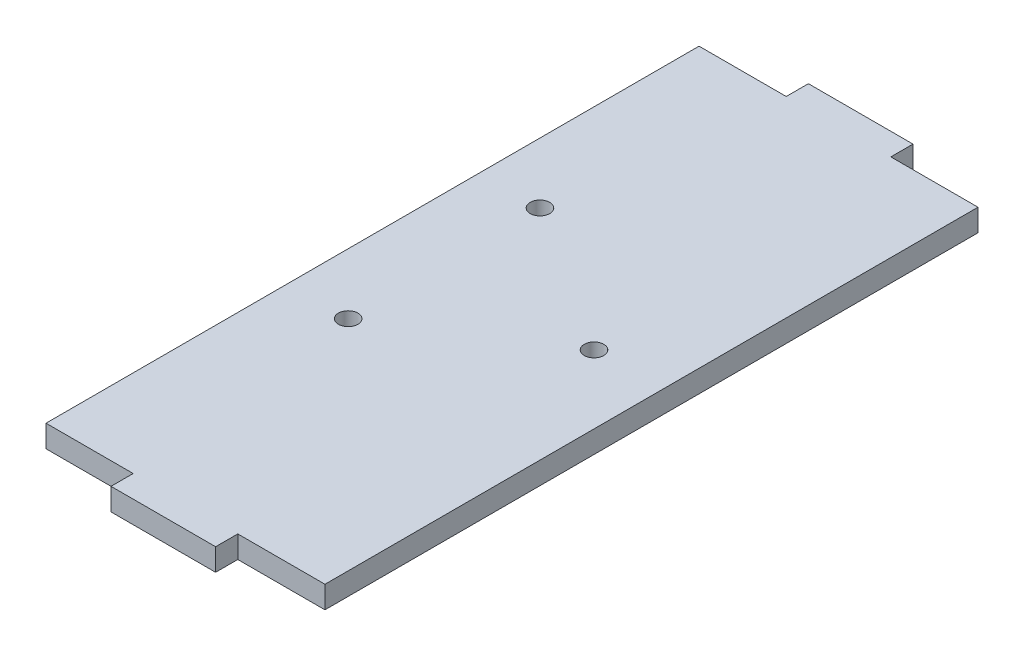
from build123d import *

# Parameters (mm, degrees)
SKETCH1_W           = 40
SKETCH1_H           = 100
BOSS_EXTRUDE1_DEPTH = 3.18
SKETCH2_W           = 12.5
SKETCH2_H           = 3.18
CUT_EXTRUDE1_DEPTH  = 4.18
SKETCH3_R           = 1.4
CUT_EXTRUDE2_DEPTH  = 4.18


with BuildPart() as part:
    # Sketch1 → Boss-Extrude1 (new body)
    with BuildSketch(Plane(origin=(0, 0, 0), x_dir=(1, 0, 0), z_dir=(0, 1, 0))):
        Rectangle(SKETCH1_W, SKETCH1_H)
    extrude(amount=BOSS_EXTRUDE1_DEPTH)

    # Sketch2 → Cut-Extrude1 (cut, through all)
    with BuildSketch(Plane(origin=(0, 3.18, 0), x_dir=(1, 0, 0), z_dir=(0, 1, 0))):
        with Locations((13.75, 48.41)):
            Rectangle(SKETCH2_W, SKETCH2_H)
        with Locations((-13.75, 48.41)):
            Rectangle(SKETCH2_W, SKETCH2_H)
    cut_extrude1 = extrude(amount=-CUT_EXTRUDE1_DEPTH, mode=Mode.SUBTRACT)

    # Mirror1: Cut-Extrude1 across plane
    add(cut_extrude1.mirror(Plane.XY), mode=Mode.SUBTRACT)

    # Sketch3 → Cut-Extrude2 (cut, through all)
    with BuildSketch(Plane(origin=(0, 3.18, 0), x_dir=(1, 0, 0), z_dir=(0, 1, 0))):
        with Locations((-11.309610499, -12.180202037)):
            Circle(SKETCH3_R)
        with Locations((10.190389501, 1.569797963)):
            Circle(SKETCH3_R)
        with Locations((-11.309610499, 15.319797963)):
            Circle(SKETCH3_R)
    extrude(amount=-CUT_EXTRUDE2_DEPTH, mode=Mode.SUBTRACT)


solid = part.part
